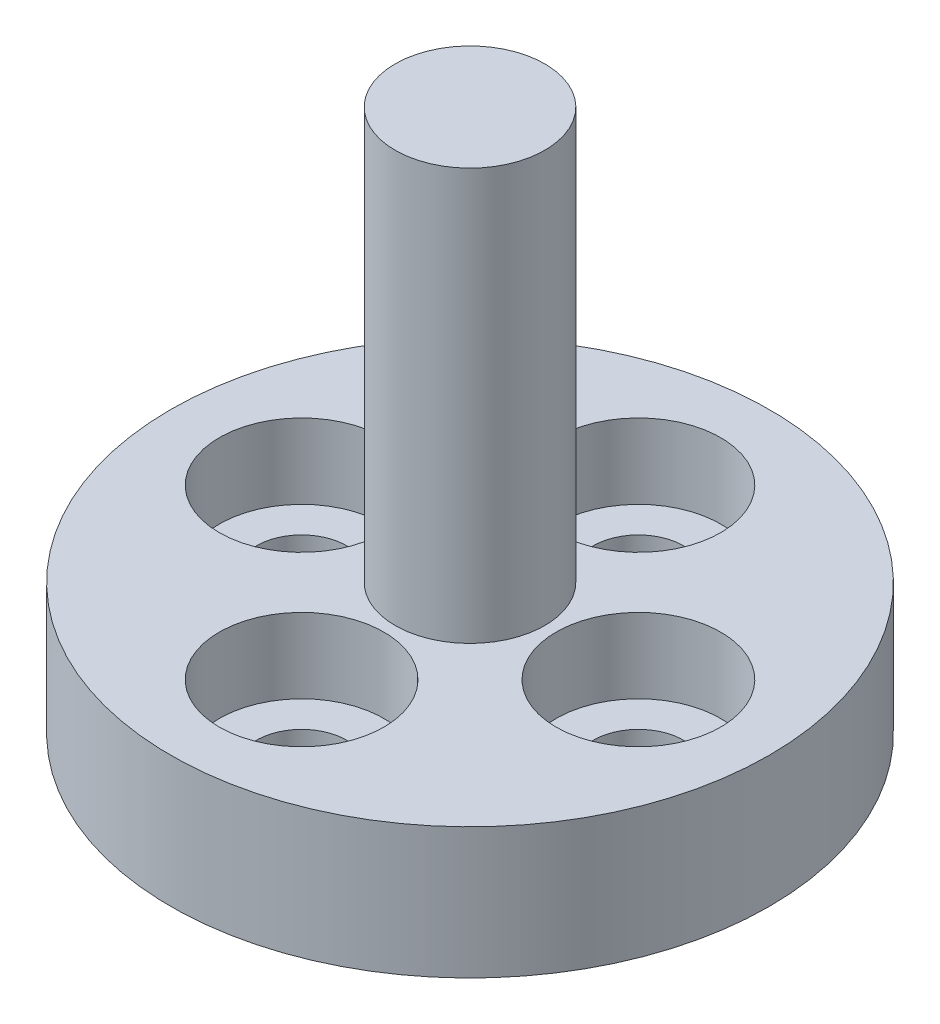
from build123d import *

# Parameters (mm, degrees)
CBORE_FOR_M2_SHCS2_D           = 2.4
CBORE_FOR_M2_SHCS2_CBORE_D     = 4.4
CBORE_FOR_M2_SHCS2_CBORE_DEPTH = 2


with BuildPart() as part:
    # Sketch3 → Revolve1 (revolve)
    with BuildSketch(Plane.XY):
        Polygon((0, 0), (8, 0), (8, 3.5), (2, 3.5), (2, 14.5), (0, 14.5), align=None)
    revolve(axis=Axis((0, 14.5, 0), (0, -1, 0)))

    # CBORE for M2 SHCS2 (through all)
    with Locations(Plane(origin=(0, 3.5, 0), x_dir=(1, 0, 0), z_dir=(0, 1, 0))):
        with Locations((4.5, 0), (0, -4.5), (0, 4.5), (-4.5, 0)):
            CounterBoreHole(CBORE_FOR_M2_SHCS2_D / 2, CBORE_FOR_M2_SHCS2_CBORE_D / 2, CBORE_FOR_M2_SHCS2_CBORE_DEPTH)


solid = part.part
